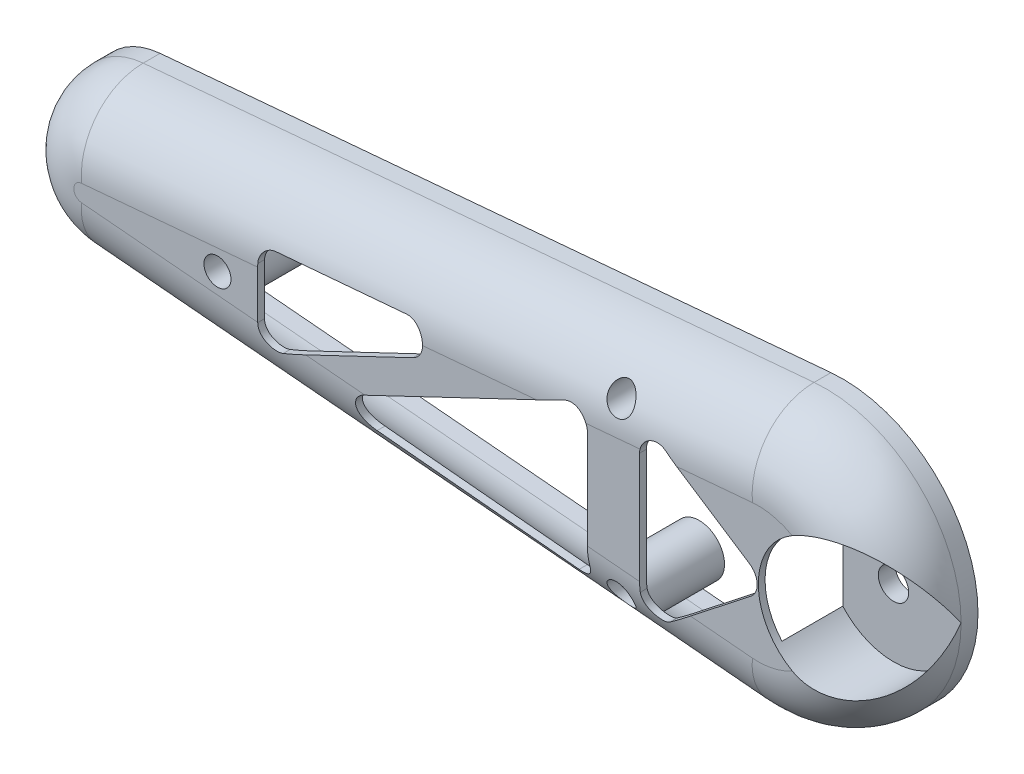
from build123d import *

# Parameters (mm, degrees)
BOSS_EXTRUDE1_DEPTH             = 25
BOSS_EXTRUDE1_DEPTH_BACK        = 25
FILLET1_R                       = 20
SHELL1_T                        = 2
CUT_EXTRUDE1_DEPTH              = 154.948043209
BOSS_EXTRUDE2_REACH             = 149.733
SKETCH4_R                       = 7.5
BOSS_EXTRUDE2_DIRECTION_2_REACH = 149.733
CUT_EXTRUDE2_DEPTH              = 148.732867071
CUT_EXTRUDE2_DEPTH_BACK         = 148.732867071
SKETCH5_R                       = 1.75
SKETCH6_R                       = 4
CUT_EXTRUDE3_DEPTH              = 12
CHAMFER1_SIZE                   = 2
SKETCH7_W                       = 361.368008509
SKETCH7_H                       = 191.328530185
CUT_EXTRUDE4_DEPTH              = 148.732867071
BOSS_EXTRUDE3_REACH             = 149.733
SKETCH9_R                       = 20
CUT_EXTRUDE5_DEPTH              = 20
SKETCH10_R                      = 4.5
CUT_EXTRUDE6_DEPTH              = 147.969384703


with BuildPart() as part:
    # Sketch1 → Boss-Extrude1 (new, two sides: drawn at the far end of the back side and taken through both)
    with BuildSketch(Plane.XY.offset(-BOSS_EXTRUDE1_DEPTH_BACK)):
        with BuildLine():
            Line((-101.96875, 22.41370169), (96.5, 39.846580782))
            ThreePointArc((96.5, 39.846580782), (140, 0), (96.5, -39.846580782))
            Line((96.5, -39.846580782), (-101.96875, -22.41370169))
            ThreePointArc((-101.96875, -22.41370169), (-122.5, 0), (-101.96875, 22.41370169))
        make_face()
    extrude(amount=BOSS_EXTRUDE1_DEPTH + BOSS_EXTRUDE1_DEPTH_BACK)

    # Fillet1
    fillet1_edges = [part.edges().sort_by_distance(p)[0] for p in [
        (-2.734375, -31.130141236, -25),
        (140, 0, -25),
        (-2.734375, 31.130141236, -25),
        (-122.5, 0, -25),
        (-2.734375, 31.130141236, 25),
        (140, 0, 25),
        (-2.734375, -31.130141236, 25),
        (-122.5, 0, 25),
    ]]
    fillet(fillet1_edges, radius=FILLET1_R)

    # Shell1 (no face opened: a closed hollow body)
    add(offset(amount=-SHELL1_T, mode=Mode.PRIVATE), mode=Mode.SUBTRACT)

    # Sketch2 → Cut-Extrude1 (cut, through all)
    with BuildSketch(Plane.XY.offset(25)):
        with BuildLine():
            Line((72.623788088, 20.082010917), (97.427080928, 3.814916262))
            ThreePointArc((97.427080928, 3.814916262), (99.680417034, -0.152425033), (97.774092642, -4.297693164))
            Line((97.774092642, -4.297693164), (72.970799802, -23.785994681))
            ThreePointArc((72.970799802, -23.785994681), (67.69600437, -24.351376347), (64.881692043, -19.854402987))
            Line((64.881692043, -19.854402987), (64.881692043, 15.900993185))
            ThreePointArc((64.881692043, 15.900993185), (67.5058217, 20.300452255), (72.623788088, 20.082010917))
        make_face()
        with BuildLine():
            Line((49.437173226, 13.583043514), (49.437173226, -20.924247919))
            ThreePointArc((49.437173226, -20.924247919), (47.779211905, -24.643223244), (43.904862239, -25.895831672))
            Line((43.904862239, -25.895831672), (-15.19932205, -19.567504869))
            ThreePointArc((-15.19932205, -19.567504869), (-19.595683588, -15.437459669), (-16.818802271, -10.082630233))
            Line((-16.818802271, -10.082630233), (42.285382017, 18.096334397))
            ThreePointArc((42.285382017, 18.096334397), (47.105603847, 17.811456695), (49.437173226, 13.583043514))
        make_face()
        with BuildLine():
            Line((-2.180462074, 6.820738981), (-40.945374431, -11.661118224))
            ThreePointArc((-40.945374431, -11.661118224), (-45.765596261, -11.376240521), (-48.09716564, -7.147827341))
            Line((-48.09716564, -7.147827341), (-48.09716564, 7.992291845))
            ThreePointArc((-48.09716564, 7.992291845), (-46.781400109, 11.372590113), (-43.526599088, 12.973816402))
            Line((-43.526599088, 12.973816402), (-4.761686731, 16.315554421))
            ThreePointArc((-4.761686731, 16.315554421), (0.492631081, 12.6457047), (-2.180462074, 6.820738981))
        make_face()
    extrude(amount=-CUT_EXTRUDE1_DEPTH, mode=Mode.SUBTRACT)

    # Sketch4 → Boss-Extrude2 (add, up to next)
    with BuildSketch(Plane.XY, mode=Mode.PRIVATE) as boss_extrude2_sk1:
        with Locations((-60, 0)):
            Circle(SKETCH4_R)
    boss_extrude2_tool1 = extrude(boss_extrude2_sk1.sketch, amount=BOSS_EXTRUDE2_REACH, mode=Mode.PRIVATE) - part.part
    # Sketch4 → Boss-Extrude2 (add, up to next)
    with BuildSketch(Plane.XY, mode=Mode.PRIVATE) as boss_extrude2_sk2:
        with Locations((57.5, 25)):
            Circle(SKETCH4_R)
    boss_extrude2_tool2 = extrude(boss_extrude2_sk2.sketch, amount=BOSS_EXTRUDE2_REACH, mode=Mode.PRIVATE) - part.part
    # Sketch4 → Boss-Extrude2 (add, up to next)
    with BuildSketch(Plane.XY, mode=Mode.PRIVATE) as boss_extrude2_sk3:
        with Locations((57.5, -25)):
            Circle(SKETCH4_R)
    boss_extrude2_tool3 = extrude(boss_extrude2_sk3.sketch, amount=BOSS_EXTRUDE2_REACH, mode=Mode.PRIVATE) - part.part
    add(boss_extrude2_tool1.solids().sort_by_distance((-60, 0, 0))[0])
    add(boss_extrude2_tool2.solids().sort_by_distance((57.5, 25, 0))[0])
    add(boss_extrude2_tool3.solids().sort_by_distance((57.5, -25, 0))[0])

    # Sketch4 → Boss-Extrude2 direction 2 (add, up to next)
    with BuildSketch(Plane.XY, mode=Mode.PRIVATE) as boss_extrude2_direction_2_sk1:
        with Locations((-60, 0)):
            Circle(SKETCH4_R)
    boss_extrude2_direction_2_tool1 = extrude(boss_extrude2_direction_2_sk1.sketch, amount=-BOSS_EXTRUDE2_DIRECTION_2_REACH, mode=Mode.PRIVATE) - part.part
    # Sketch4 → Boss-Extrude2 direction 2 (add, up to next)
    with BuildSketch(Plane.XY, mode=Mode.PRIVATE) as boss_extrude2_direction_2_sk2:
        with Locations((57.5, 25)):
            Circle(SKETCH4_R)
    boss_extrude2_direction_2_tool2 = extrude(boss_extrude2_direction_2_sk2.sketch, amount=-BOSS_EXTRUDE2_DIRECTION_2_REACH, mode=Mode.PRIVATE) - part.part
    # Sketch4 → Boss-Extrude2 direction 2 (add, up to next)
    with BuildSketch(Plane.XY, mode=Mode.PRIVATE) as boss_extrude2_direction_2_sk3:
        with Locations((57.5, -25)):
            Circle(SKETCH4_R)
    boss_extrude2_direction_2_tool3 = extrude(boss_extrude2_direction_2_sk3.sketch, amount=-BOSS_EXTRUDE2_DIRECTION_2_REACH, mode=Mode.PRIVATE) - part.part
    add(boss_extrude2_direction_2_tool1.solids().sort_by_distance((-60, 0, 0))[0])
    add(boss_extrude2_direction_2_tool2.solids().sort_by_distance((57.5, 25, 0))[0])
    add(boss_extrude2_direction_2_tool3.solids().sort_by_distance((57.5, -25, 0))[0])

    # Sketch5 → Cut-Extrude2 (cut, two sides: drawn at the far end of the back side and taken through both)
    with BuildSketch(Plane.XY.offset(-CUT_EXTRUDE2_DEPTH_BACK)):
        with Locations((57.5, 25)):
            Circle(SKETCH5_R)
        with Locations((57.5, -25)):
            Circle(SKETCH5_R)
        with Locations((-60, 0)):
            Circle(SKETCH5_R)
    extrude(amount=CUT_EXTRUDE2_DEPTH + CUT_EXTRUDE2_DEPTH_BACK, mode=Mode.SUBTRACT)

    # Sketch6 → Cut-Extrude3 (cut)
    with BuildSketch(Plane.XY.offset(25)):
        with Locations((57.5, 25)):
            Circle(SKETCH6_R)
        with Locations((57.5, -25)):
            Circle(SKETCH6_R)
        with Locations((-60, 0)):
            Circle(SKETCH6_R)
    cut_extrude3 = extrude(amount=-CUT_EXTRUDE3_DEPTH, mode=Mode.SUBTRACT)

    # Mirror1: Cut-Extrude3 across plane
    add(cut_extrude3.mirror(Plane.XY), mode=Mode.SUBTRACT)

    # Chamfer1
    chamfer1_edges = [part.edges().sort_by_distance(p)[0] for p in [
        (53.5, -25, 13),
        (53.5, 25, 13),
        (-64, 0, 13),
        (-64, 0, -13),
        (53.5, -25, -13),
        (53.5, 25, -13),
    ]]
    chamfer(chamfer1_edges, length=CHAMFER1_SIZE)

    # Sketch7 → Cut-Extrude4 (cut, through all)
    with BuildSketch(Plane.XY):
        with Locations((9.022936562, -5.185794685)):
            Rectangle(SKETCH7_W, SKETCH7_H)
    extrude(amount=-CUT_EXTRUDE4_DEPTH, mode=Mode.SUBTRACT)

    # Sketch8 → Boss-Extrude3 (add, up to next)
    with BuildSketch(Plane(origin=(0, 0, 0), x_dir=(-1, 0, 0), z_dir=(0, 0, -1)), mode=Mode.PRIVATE) as boss_extrude3_sk1:
        with BuildLine():
            Line((-105, 37.669616404), (-105, -37.669616404))
            ThreePointArc((-105, -37.669616404), (-138, 0), (-105, 37.669616404))
        make_face()
    boss_extrude3_tool1 = extrude(boss_extrude3_sk1.sketch, amount=-BOSS_EXTRUDE3_REACH, mode=Mode.PRIVATE) - part.part
    add(boss_extrude3_tool1.solids().sort_by_distance((118.861433, 0, 0))[0])

    # Sketch9 → Cut-Extrude5 (cut)
    with BuildSketch(Plane.XY.offset(25)):
        with Locations((120, 0)):
            Circle(SKETCH9_R)
    extrude(amount=-CUT_EXTRUDE5_DEPTH, mode=Mode.SUBTRACT)

    # Sketch10 → Cut-Extrude6 (cut, through all)
    with BuildSketch(Plane.XY.offset(5)):
        with Locations((120, 0)):
            Circle(SKETCH10_R)
    extrude(amount=-CUT_EXTRUDE6_DEPTH, mode=Mode.SUBTRACT)


solid = part.part
